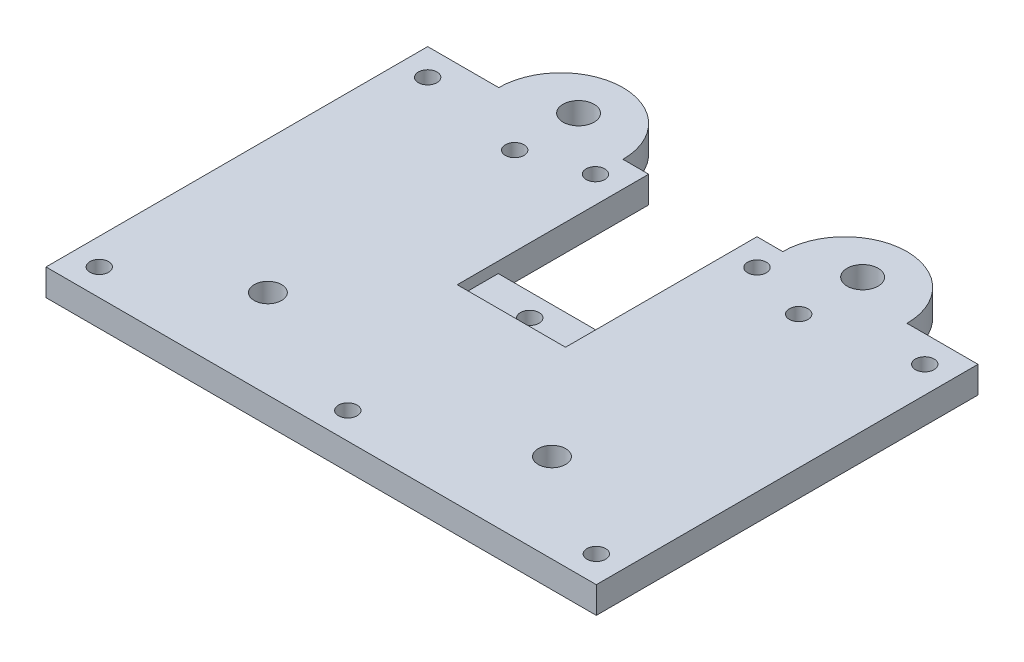
from build123d import *

# Parameters (mm, degrees)
SKETCH_1_R               = 1.05
SKETCH_1_R_2             = 1.55
SKETCH_1_R_3             = 1.75
EXTRUDE_1_DEPTH          = 3
CUT_EXTRUDE_1_DEPTH      = 10
SKETCH_5_W               = 12.2
SKETCH_5_H               = 4.62
CUT_EXTRUDE_3_DEPTH      = 1
CUT_EXTRUDE_3_DEPTH_BACK = 1.22


with BuildPart() as part:
    # 草图1 → 凸台-拉伸1 (new body)
    with BuildSketch(Plane(origin=(0, 0, 0), x_dir=(1, 0, 0), z_dir=(0, 1, 0))):
        with BuildLine():
            Line((0, 43), (0, 0))
            Line((0, 0), (62, 0))
            Line((62, 0), (62, 43))
            Line((62, 43), (54, 43))
            ThreePointArc((54, 43), (47, 50), (40, 43))
            Line((40, 43), (22, 43))
            ThreePointArc((22, 43), (15, 50), (8, 43))
            Line((8, 43), (0, 43))
        make_face()
        with Locations((3, 3)):
            Circle(SKETCH_1_R, mode=Mode.SUBTRACT)
        with Locations((15, 10)):
            Circle(SKETCH_1_R_2, mode=Mode.SUBTRACT)
        with Locations((31, 3)):
            Circle(SKETCH_1_R, mode=Mode.SUBTRACT)
        with Locations((59, 3)):
            Circle(SKETCH_1_R, mode=Mode.SUBTRACT)
        with Locations((47, 10)):
            Circle(SKETCH_1_R_2, mode=Mode.SUBTRACT)
        with Locations((31, 23.5)):
            Circle(SKETCH_1_R, mode=Mode.SUBTRACT)
        with Locations((3, 40)):
            Circle(SKETCH_1_R, mode=Mode.SUBTRACT)
        with Locations((15, 37.8)):
            Circle(SKETCH_1_R, mode=Mode.SUBTRACT)
        with Locations((21.9, 40)):
            Circle(SKETCH_1_R, mode=Mode.SUBTRACT)
        with Locations((40.1, 40)):
            Circle(SKETCH_1_R, mode=Mode.SUBTRACT)
        with Locations((47, 37.8)):
            Circle(SKETCH_1_R, mode=Mode.SUBTRACT)
        with Locations((59, 40)):
            Circle(SKETCH_1_R, mode=Mode.SUBTRACT)
        with Locations((15, 45)):
            Circle(SKETCH_1_R_3, mode=Mode.SUBTRACT)
        with Locations((47, 45)):
            Circle(SKETCH_1_R_3, mode=Mode.SUBTRACT)
    extrude(amount=EXTRUDE_1_DEPTH)

    # 草图2 → 切除-拉伸1 (cut)
    with BuildSketch(Plane(origin=(0, 3, 0), x_dir=(1, 0, 0), z_dir=(0, 1, 0))):
        Polygon((31, 43), (37.1, 43), (37.1, 26.05), (24.9, 26.05), (24.9, 43), align=None)
    extrude(amount=-CUT_EXTRUDE_1_DEPTH, mode=Mode.SUBTRACT)

    # 草图5 → 切除-拉伸3 (cut, two sides)
    with BuildSketch(Plane(origin=(0, 3, 0), x_dir=(1, 0, 0), z_dir=(0, 1, 0))) as cut_extrude_3_sk:
        with Locations((31, 23.74)):
            Rectangle(SKETCH_5_W, SKETCH_5_H)
    extrude(amount=CUT_EXTRUDE_3_DEPTH, mode=Mode.SUBTRACT)
    extrude(cut_extrude_3_sk.sketch, amount=-CUT_EXTRUDE_3_DEPTH_BACK, mode=Mode.SUBTRACT)


solid = part.part
